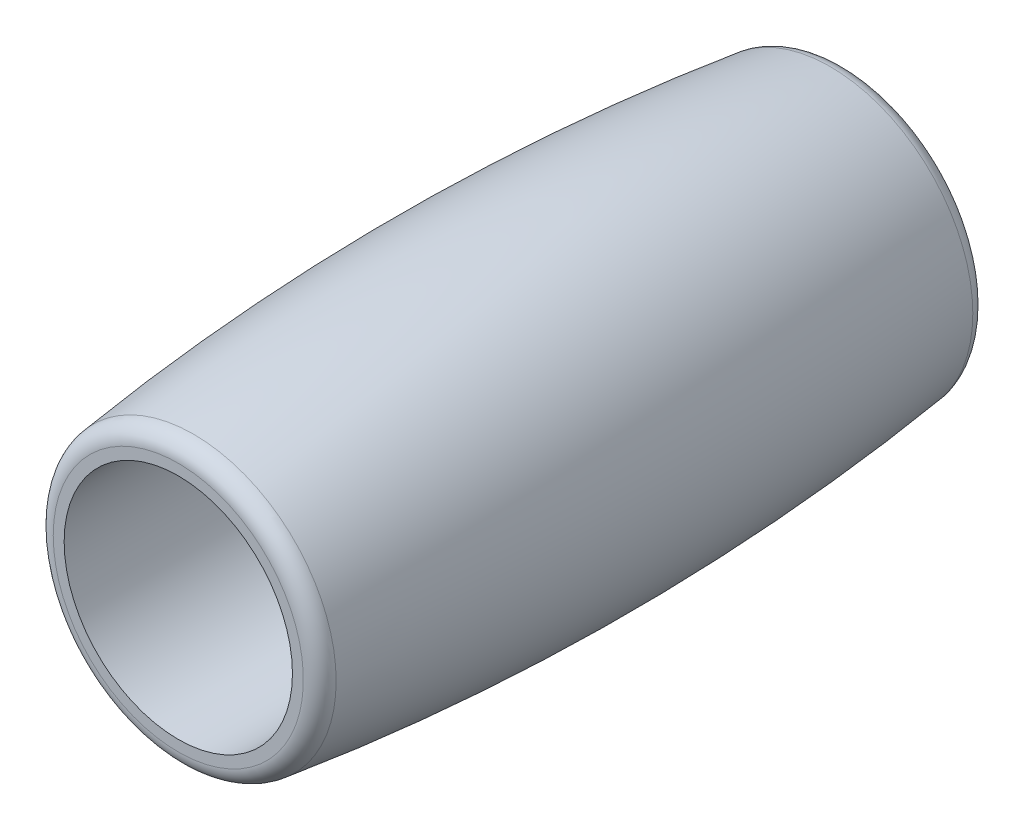
from build123d import *

# Parameters (mm, degrees)
FILLET_1_R = 1
FILLET_2_R = 1


with BuildPart() as part:
    # 草图1 → 旋转1 (revolve)
    with BuildSketch(Plane(origin=(0, 0, 0), x_dir=(1, 0, 0), z_dir=(0, 1, 0))):
        with BuildLine():
            Line((8, 19.597114905), (6.5, 19.597114905))
            Line((6.5, 19.597114905), (6.5, -18.402885095))
            Line((6.5, -18.402885095), (8, -18.402885095))
            ThreePointArc((8, -18.402885095), (9.25, 0.597114905), (8, 19.597114905))
        make_face()
    revolve(axis=Axis((0, 0, -17.560419169), (0, 0, 1)))

    # 圆角1
    fillet_1_edges = [part.edges().sort_by_distance(p)[0] for p in [
        (-8, 0, 18.402885095),
    ]]
    fillet(fillet_1_edges, radius=FILLET_1_R)

    # 圆角2
    fillet_2_edges = [part.edges().sort_by_distance(p)[0] for p in [
        (-8, 0, -19.597114905),
    ]]
    fillet(fillet_2_edges, radius=FILLET_2_R)


solid = part.part
